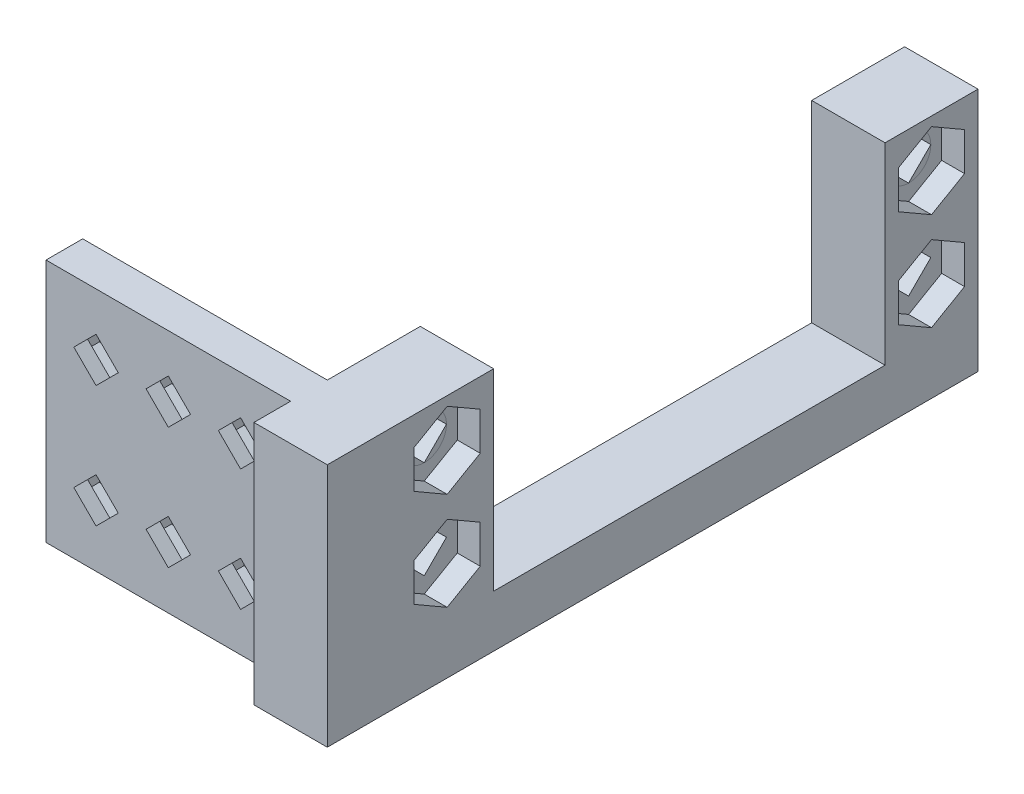
from build123d import *

# Parameters (mm, degrees)
BOSS_EXTRUDE1_DEPTH = 12.7
SKETCH2_W           = 7.62
SKETCH2_H           = 40.64
CUT_EXTRUDE1_DEPTH  = 20
CUT_EXTRUDE2_DEPTH  = 34.02
CUT_EXTRUDE6_DEPTH  = 2.38125
CUT_EXTRUDE5_DEPTH  = 8.62
CUT_EXTRUDE7_DEPTH  = 2.38125
SKETCH14_W          = 25.4
SKETCH14_H          = 3.81
CUT_EXTRUDE8_DEPTH  = 26.4


with BuildPart() as part:
    # Sketch1 → Boss-Extrude1 (new body, symmetric)
    with BuildSketch(Plane(origin=(0, 0, 0), x_dir=(1, 0, 0), z_dir=(0, 1, 0))):
        Polygon((0, 59.944), (0, 0), (-25.4, 0), (-25.4, -7.62), (7.62, -7.62), (7.62, 59.944), align=None)
    extrude(amount=BOSS_EXTRUDE1_DEPTH, both=True)

    # Sketch2 → Cut-Extrude1 (cut)
    with BuildSketch(Plane(origin=(0, 12.7, 0), x_dir=(1, 0, 0), z_dir=(0, 1, 0))):
        with Locations((3.81, 29.972)):
            Rectangle(SKETCH2_W, SKETCH2_H)
    extrude(amount=-CUT_EXTRUDE1_DEPTH, mode=Mode.SUBTRACT)

    # Sketch3 → Cut-Extrude2 (cut, through all)
    with BuildSketch(Plane(origin=(7.62, 0, 0), x_dir=(0, 0, -1), z_dir=(1, 0, 0))):
        Polygon((55.118, 10.087925823), (52.810074177, 7.78), (55.118, 5.472074177), (57.425925823, 7.78), align=None)
        Polygon((2.518074177, 7.78), (4.826, 5.472074177), (7.133925823, 7.78), (4.826, 10.087925823), align=None)
        Polygon((57.425925823, -2.38), (55.118, -0.072074177), (52.810074177, -2.38), (55.118, -4.687925823), align=None)
        Polygon((4.826, -4.687925823), (7.133925823, -2.38), (4.826, -0.072074177), (2.518074177, -2.38), align=None)
    extrude(amount=-CUT_EXTRUDE2_DEPTH, mode=Mode.SUBTRACT)

    # Sketch12 → Cut-Extrude6 (cut)
    with BuildSketch(Plane(origin=(7.62, 0, 0), x_dir=(0, 0, -1), z_dir=(1, 0, 0))):
        Polygon((8.255, 9.759734073), (4.826, 11.739468146), (1.397, 9.759734073), (1.397, 5.800265927), (4.826, 3.820531854), (8.255, 5.800265927), align=None)
        Polygon((4.826, 1.579468146), (1.397, -0.400265927), (1.397, -4.359734073), (4.826, -6.339468146), (8.255, -4.359734073), (8.255, -0.400265927), align=None)
        Polygon((55.118, 1.579468146), (51.689, -0.400265927), (51.689, -4.359734073), (55.118, -6.339468146), (58.547, -4.359734073), (58.547, -0.400265927), align=None)
        Polygon((55.118, 11.739468146), (51.689, 9.759734073), (51.689, 5.800265927), (55.118, 3.820531854), (58.547, 5.800265927), (58.547, 9.759734073), align=None)
    extrude(amount=-CUT_EXTRUDE6_DEPTH, mode=Mode.SUBTRACT)

    # Sketch9 → Cut-Extrude5 (cut, through all)
    with BuildSketch(Plane(origin=(0, 0, 0), x_dir=(-1, 0, 0), z_dir=(0, 0, -1))):
        Polygon((5.196037088, 4.006037088), (7.503962912, 6.313962912), (5.196037088, 8.621888735), (2.888111265, 6.313962912), align=None)
        Polygon((20.203962912, 4.006037088), (22.511888735, 6.313962912), (20.203962912, 8.621888735), (17.896037088, 6.313962912), align=None)
        Polygon((12.7, 4.006037088), (15.007925823, 6.313962912), (12.7, 8.621888735), (10.392074177, 6.313962912), align=None)
    cut_extrude5 = extrude(amount=-CUT_EXTRUDE5_DEPTH, mode=Mode.SUBTRACT)

    # Sketch13 → Cut-Extrude7 (cut)
    with BuildSketch(Plane(origin=(0, 0, 0), x_dir=(-1, 0, 0), z_dir=(0, 0, -1))):
        Polygon((8.625037088, 4.334228839), (8.625037088, 8.293696985), (5.196037088, 10.273431058), (1.767037088, 8.293696985), (1.767037088, 4.334228839), (5.196037088, 2.354494765), align=None)
        Polygon((12.7, 2.354494765), (16.129, 4.334228839), (16.129, 8.293696985), (12.7, 10.273431058), (9.271, 8.293696985), (9.271, 4.334228839), align=None)
        Polygon((20.203962912, 2.354494765), (23.632962912, 4.334228839), (23.632962912, 8.293696985), (20.203962912, 10.273431058), (16.774962912, 8.293696985), (16.774962912, 4.334228839), align=None)
    cut_extrude7 = extrude(amount=-CUT_EXTRUDE7_DEPTH, mode=Mode.SUBTRACT)

    # Mirror2: Cut-Extrude5, Cut-Extrude7 across plane
    add(cut_extrude5.mirror(Plane.ZX), mode=Mode.SUBTRACT)
    add(cut_extrude7.mirror(Plane.ZX), mode=Mode.SUBTRACT)

    # Sketch14 → Cut-Extrude8 (cut, through all)
    with BuildSketch(Plane(origin=(0, 12.7, 0), x_dir=(1, 0, 0), z_dir=(0, 1, 0))):
        with Locations((-12.7, -5.715)):
            Rectangle(SKETCH14_W, SKETCH14_H)
    extrude(amount=-CUT_EXTRUDE8_DEPTH, mode=Mode.SUBTRACT)


solid = part.part
